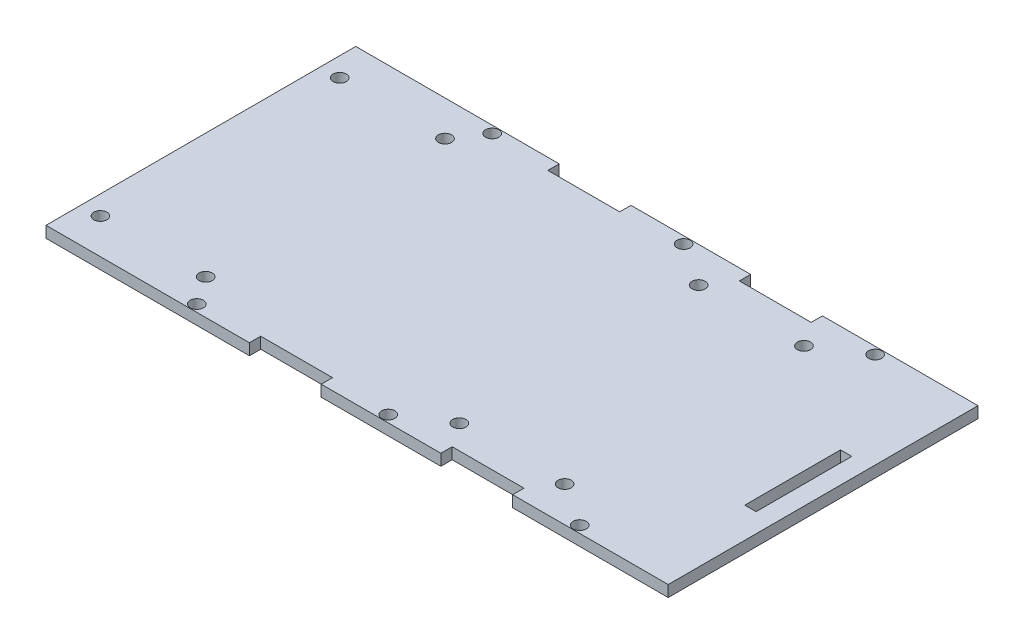
from build123d import *

# Parameters (mm, degrees)
SKETCH1_R           = 1.7526
SKETCH1_W           = 3
SKETCH1_H           = 25.4
BOSS_EXTRUDE1_DEPTH = 3
SKETCH2_R           = 1.7526
CUT_EXTRUDE1_DEPTH  = 4


with BuildPart() as part:
    # Sketch1 → Boss-Extrude1 (new body)
    with BuildSketch(Plane(origin=(0, 0, 0), x_dir=(1, 0, 0), z_dir=(0, 1, 0))):
        Polygon((-114.3, 41.1), (-77.528882775, 41.1), (-74.871117225, 41.1), (-60.325, 41.1), (-60.325, 38.1), (-41.275, 38.1), (-41.275, 41.1), (-26.728882775, 41.1), (-24.071117225, 41.1), (-9.525, 41.1), (-9.525, 38.1), (9.525, 38.1), (9.525, 41.1), (24.071117225, 41.1), (26.728882775, 41.1), (50.8, 41.1), (50.8, -41.1), (26.728882775, -41.1), (24.071117225, -41.1), (9.525, -41.1), (9.525, -38.1), (-9.525, -38.1), (-9.525, -41.1), (-24.071117225, -41.1), (-26.728882775, -41.1), (-41.275, -41.1), (-41.275, -38.1), (-60.325, -38.1), (-60.325, -41.1), (-74.871117225, -41.1), (-77.528882775, -41.1), (-114.3, -41.1), align=None)
        with Locations((-25.4, -39.195)):
            Circle(SKETCH1_R, mode=Mode.SUBTRACT)
        with Locations((25.4, -39.195)):
            Circle(SKETCH1_R, mode=Mode.SUBTRACT)
        with Locations((25.4, 39.195)):
            Circle(SKETCH1_R, mode=Mode.SUBTRACT)
        with Locations((-25.4, 39.195)):
            Circle(SKETCH1_R, mode=Mode.SUBTRACT)
        with Locations((-76.2, 39.195)):
            Circle(SKETCH1_R, mode=Mode.SUBTRACT)
        with Locations((-76.2, -39.195)):
            Circle(SKETCH1_R, mode=Mode.SUBTRACT)
        with Locations((44.22, 0)):
            Rectangle(SKETCH1_W, SKETCH1_H, mode=Mode.SUBTRACT)
    extrude(amount=BOSS_EXTRUDE1_DEPTH)

    # Sketch2 → Cut-Extrude1 (cut, through all)
    with BuildSketch(Plane(origin=(0, 3, 0), x_dir=(1, 0, 0), z_dir=(0, 1, 0))):
        with Locations((-109.22, -31.75)):
            Circle(SKETCH2_R)
        with Locations((-81.28, -31.75)):
            Circle(SKETCH2_R)
        with Locations((13.97, -31.75)):
            Circle(SKETCH2_R)
        with Locations((-13.97, -31.75)):
            Circle(SKETCH2_R)
    cut_extrude1 = extrude(amount=-CUT_EXTRUDE1_DEPTH, mode=Mode.SUBTRACT)

    # Mirror1: Cut-Extrude1 across plane
    add(cut_extrude1.mirror(Plane.XY), mode=Mode.SUBTRACT)


solid = part.part
